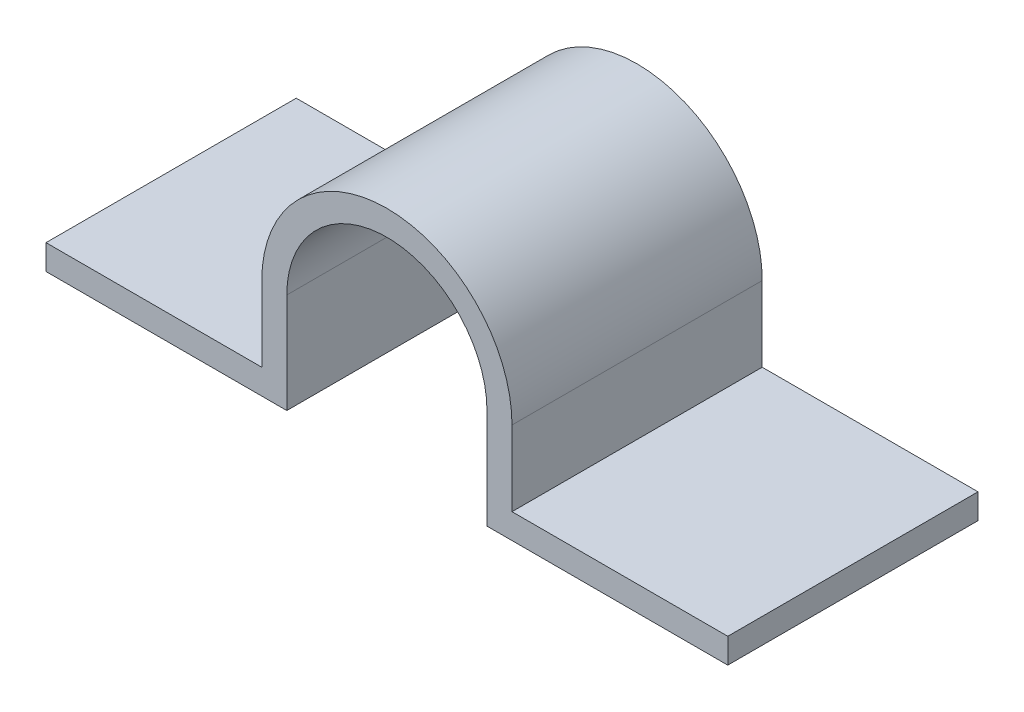
from build123d import *

# Parameters (mm, degrees)
EXTRUDE_1_DEPTH = 10


with BuildPart() as part:
    # 草图1 → 凸台-拉伸1 (new body)
    with BuildSketch(Plane.XY):
        with BuildLine():
            Line((5, 4), (5, 1))
            Line((5, 1), (13.623322376, 1))
            Line((13.623322376, 1), (13.623322376, 0))
            Line((13.623322376, 0), (4, 0))
            Line((4, 0), (4, 4))
            ThreePointArc((4, 4), (0, 8), (-4, 4))
            Line((-4, 4), (-4, 0))
            Line((-4, 0), (-13.623322376, 0))
            Line((-13.623322376, 0), (-13.623322376, 1))
            Line((-13.623322376, 1), (-5, 1))
            Line((-5, 1), (-5, 4))
            ThreePointArc((-5, 4), (0, 9), (5, 4))
        make_face()
    extrude(amount=EXTRUDE_1_DEPTH)


solid = part.part
